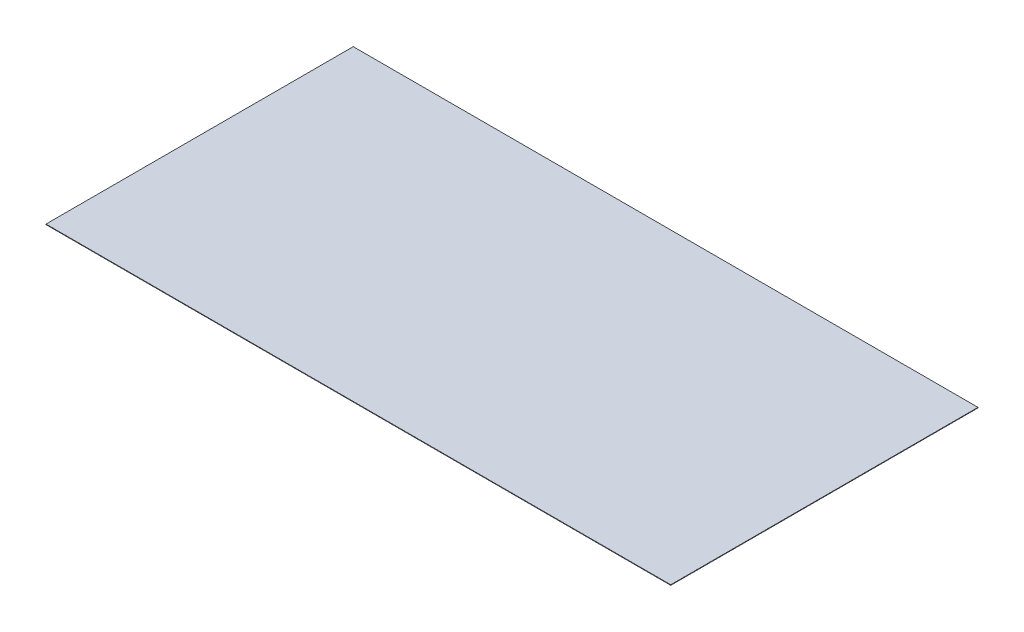
from build123d import *

# Parameters (mm, degrees)
SKETCH1_W           = 2440
SKETCH1_H           = 1200
BOSS_EXTRUDE1_DEPTH = 2


with BuildPart() as part:
    # Sketch1 → Boss-Extrude1 (new body)
    with BuildSketch(Plane(origin=(0, 0, 0), x_dir=(1, 0, 0), z_dir=(0, 1, 0))):
        Rectangle(SKETCH1_W, SKETCH1_H)
    extrude(amount=BOSS_EXTRUDE1_DEPTH)


solid = part.part
